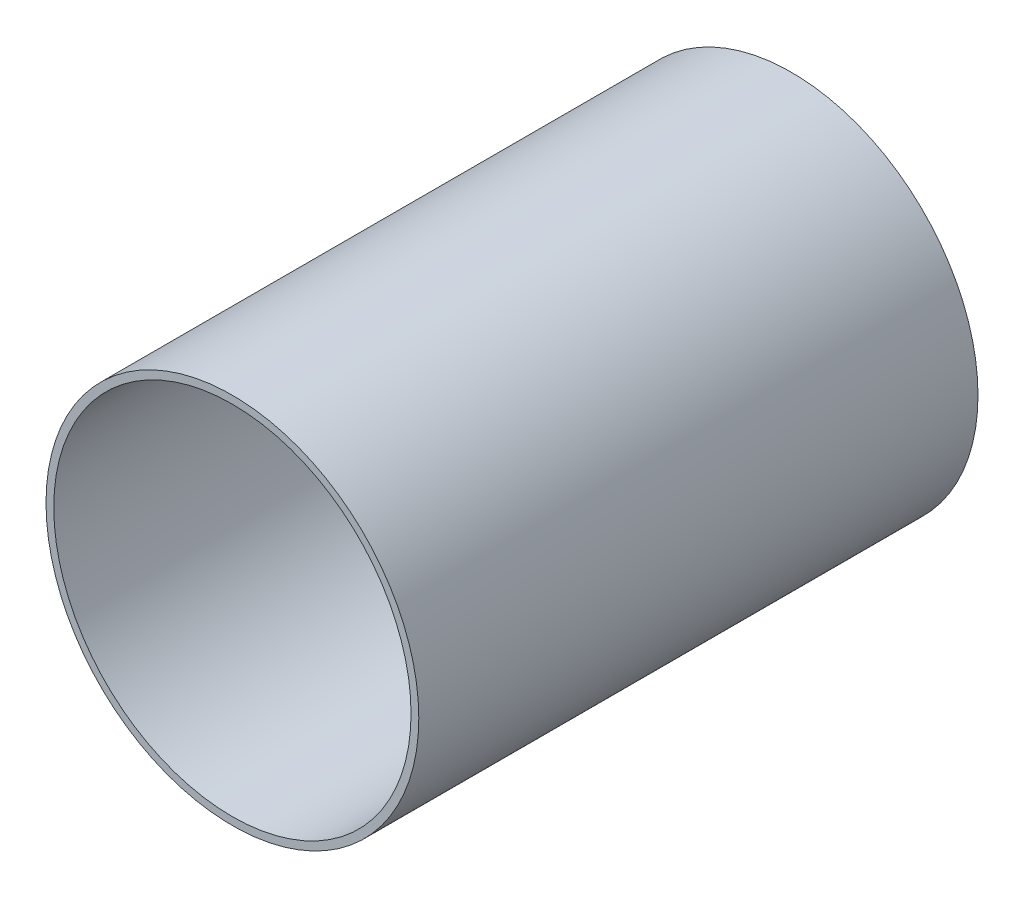
from build123d import *

# Parameters (mm, degrees)
SKETCH1_R           = 76.2
SKETCH1_R_2         = 73.025
BOSS_EXTRUDE1_DEPTH = 228.6


with BuildPart() as part:
    # Sketch1 → Boss-Extrude1 (new body)
    with BuildSketch(Plane.XY):
        Circle(SKETCH1_R)
        Circle(SKETCH1_R_2, mode=Mode.SUBTRACT)
    extrude(amount=BOSS_EXTRUDE1_DEPTH)


solid = part.part
